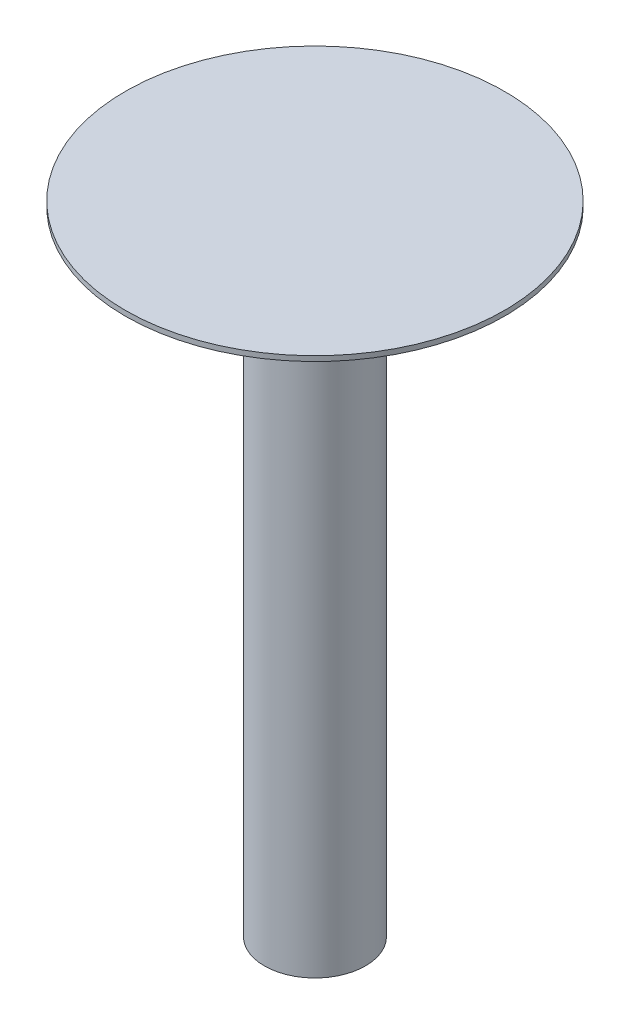
from build123d import *

# Parameters (mm, degrees)
ESQUISSE1_R      = 20
EXTRUSION1_DEPTH = 250
ESQUISSE2_R      = 75
EXTRUSION2_DEPTH = 2


with BuildPart() as part:
    # Esquisse1 → Extrusion1 (new body)
    with BuildSketch(Plane(origin=(0, 0, 0), x_dir=(1, 0, 0), z_dir=(0, 1, 0))):
        Circle(ESQUISSE1_R)
    extrude(amount=EXTRUSION1_DEPTH)

    # Esquisse2 → Extrusion2 (add)
    with BuildSketch(Plane(origin=(0, 250, 0), x_dir=(-1, 0, 0), z_dir=(0, 1, 0))):
        Circle(ESQUISSE2_R)
    extrude(amount=EXTRUSION2_DEPTH)


solid = part.part
